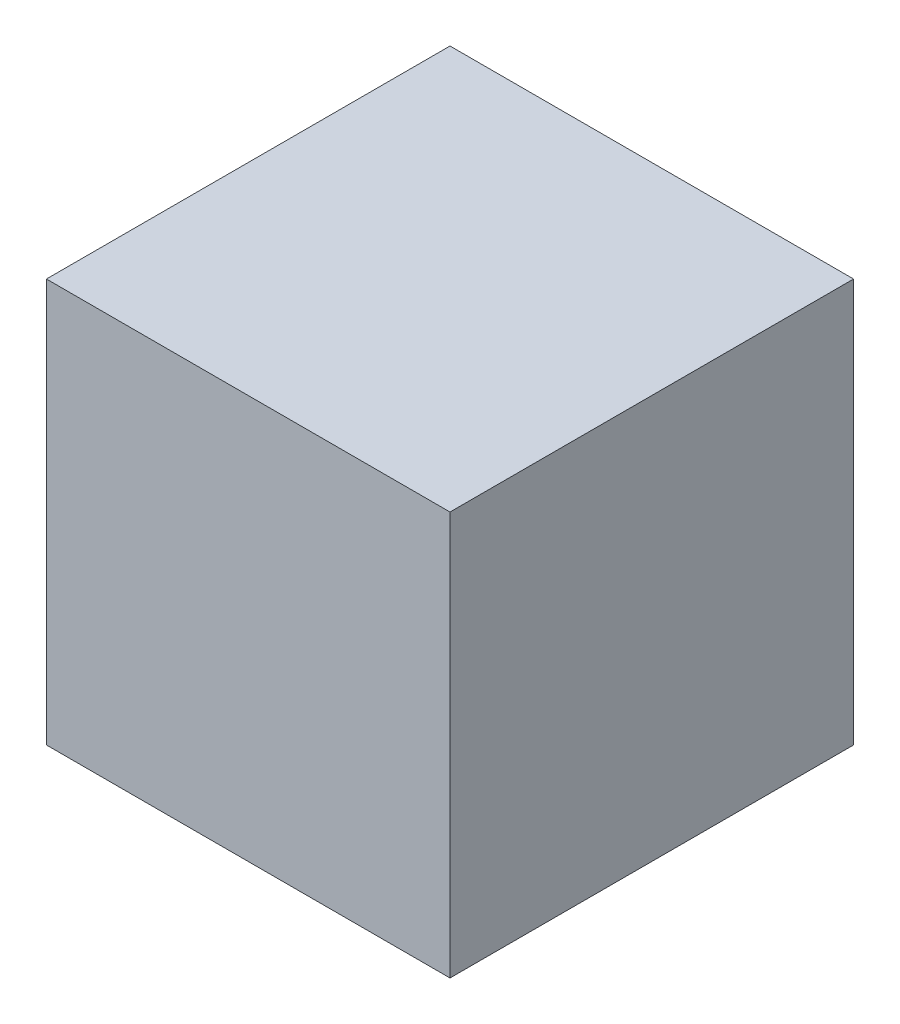
from build123d import *

# Parameters (mm, degrees)
SKIZZE1_W                       = 25
SKIZZE1_H                       = 25
AUFSATZ_LINEAR_AUSTRAGEN1_DEPTH = 12.5


with BuildPart() as part:
    # Skizze1 → Aufsatz-Linear austragen1 (new body, symmetric)
    with BuildSketch(Plane.XY):
        Rectangle(SKIZZE1_W, SKIZZE1_H)
    extrude(amount=AUFSATZ_LINEAR_AUSTRAGEN1_DEPTH, both=True)


solid = part.part
